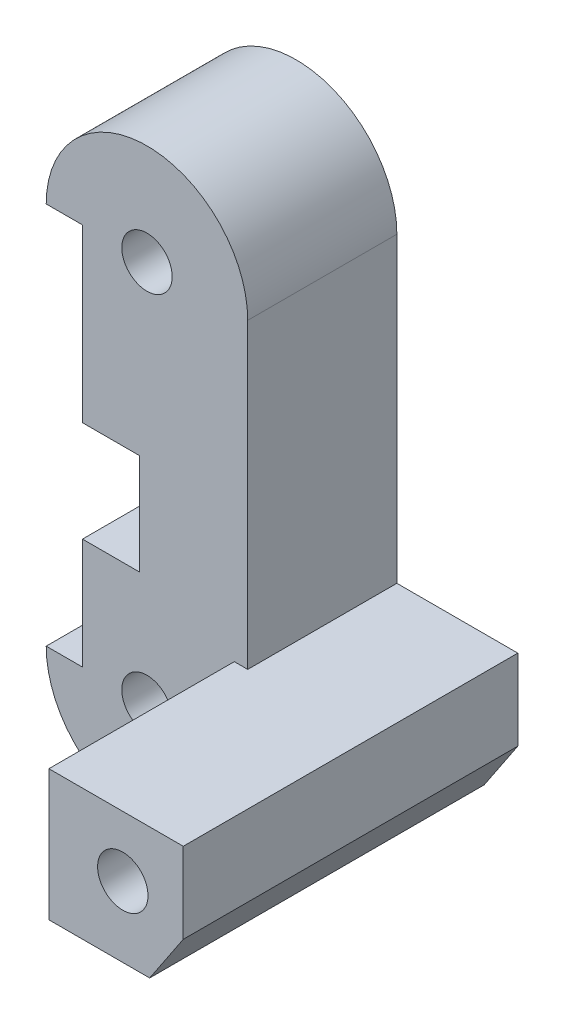
from build123d import *

# Parameters (mm, degrees)
EXTRUDE_1_DEPTH        = 7.4
EXTRUDE_2_DEPTH        = 9.2
HOLE_WIZARD_M3_1_D     = 2.5
HOLE_WIZARD_M3_1_DEPTH = 6.5
HOLE_WIZARD_M3_1_TIP   = 0.751075774
HOLE_WIZARD_M3_3_D     = 2.5
HOLE_WIZARD_M3_4_D     = 2.5
FILLET_1_R             = 2
CUT_EXTRUDE_1_DEPTH    = 5


with BuildPart() as part:
    # 草图1 → 凸台-拉伸1 (new body)
    with BuildSketch(Plane.XY):
        with BuildLine():
            Line((-3.2, 19), (-3.2, 0))
            Line((-3.2, 0), (-5, 0))
            ThreePointArc((-5, 0), (-1.290994449, -4.830458915), (4.333333333, -2.494438258))
            Line((4.333333333, -2.494438258), (9.333333333, -2.494438258))
            Line((9.333333333, -2.494438258), (11, 0))
            Line((11, 0), (11, 4))
            Line((11, 4), (5, 4))
            Line((5, 4), (5, 19))
            ThreePointArc((5, 19), (0, 24), (-5, 19))
            Line((-5, 19), (-3.2, 19))
        make_face()
    extrude(amount=EXTRUDE_1_DEPTH)

    # 草图2 → 凸台-拉伸2 (add)
    with BuildSketch(Plane.XY.offset(7.4)):
        Polygon((11, 4), (5, 4), (4.333333333, 4), (4.333333333, -2.494438258), (9.333333333, -2.494438258), (11, 0), align=None)
    extrude(amount=EXTRUDE_2_DEPTH)

    # M3 螺纹孔1
    with Locations(Plane(origin=(-3.2, 14, 4.4), x_dir=(0, -1, 0), z_dir=(-1, 0, 0))):
        with Locations((0, 0), (10, 0)):
            Hole(HOLE_WIZARD_M3_1_D / 2, depth=HOLE_WIZARD_M3_1_DEPTH)
            with Locations((0, 0, -(HOLE_WIZARD_M3_1_DEPTH + HOLE_WIZARD_M3_1_TIP / 2))):  # 118° drill point
                Cone(0, HOLE_WIZARD_M3_1_D / 2, HOLE_WIZARD_M3_1_TIP, mode=Mode.SUBTRACT)

    # M3 螺纹孔3 (through all)
    with Locations(Plane.XY.offset(7.4)):
        with Locations((0, 0), (0, 19)):
            Hole(HOLE_WIZARD_M3_3_D / 2)

    # M3 螺纹孔4 (through all)
    with Locations(Plane(origin=(8, 1, 16.6), x_dir=(1, 0, 0), z_dir=(0, 0, 1))):
        with Locations((0, 0)):
            Hole(HOLE_WIZARD_M3_4_D / 2)

    # 圆角1
    fillet_1_edges = [part.edges().sort_by_distance(p)[0] for p in [
        (4.333333333, -2.494438258, 3.7),
    ]]
    fillet(fillet_1_edges, radius=FILLET_1_R)

    # 草图10 → 切除-拉伸1 (cut)
    with BuildSketch(Plane(origin=(0, 5.5, 0), x_dir=(1, 0, 0), z_dir=(0, 1, 0))):
        Polygon((-3.2, -7.4), (-0.371572875, -7.4), (-3.2, -4.571572875), align=None)
    extrude(amount=CUT_EXTRUDE_1_DEPTH, mode=Mode.SUBTRACT)


solid = part.part
